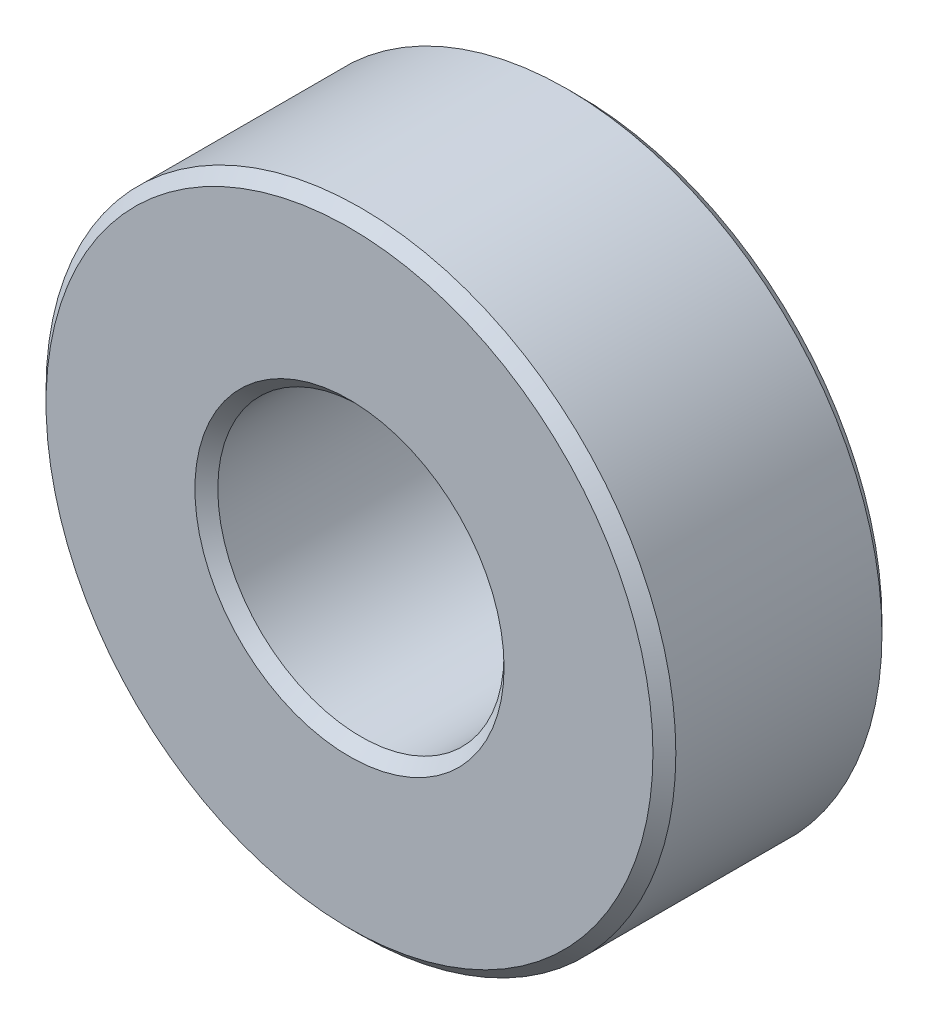
from build123d import *

# Parameters (mm, degrees)
SKETCH1_R           = 5.5
SKETCH1_R_2         = 2.5
BOSS_EXTRUDE1_DEPTH = 4
CHAMFER1_SIZE       = 0.2


with BuildPart() as part:
    # Sketch1 → Boss-Extrude1 (new body)
    with BuildSketch(Plane.XY):
        Circle(SKETCH1_R)
        Circle(SKETCH1_R_2, mode=Mode.SUBTRACT)
    extrude(amount=BOSS_EXTRUDE1_DEPTH)

    # Chamfer1
    chamfer1_edges = [part.edges().sort_by_distance(p)[0] for p in [
        (-5.5, 0, 0),
        (-5.5, 0, 4),
        (-2.5, 0, 0),
        (-2.5, 0, 4),
    ]]
    chamfer(chamfer1_edges, length=CHAMFER1_SIZE)


solid = part.part
